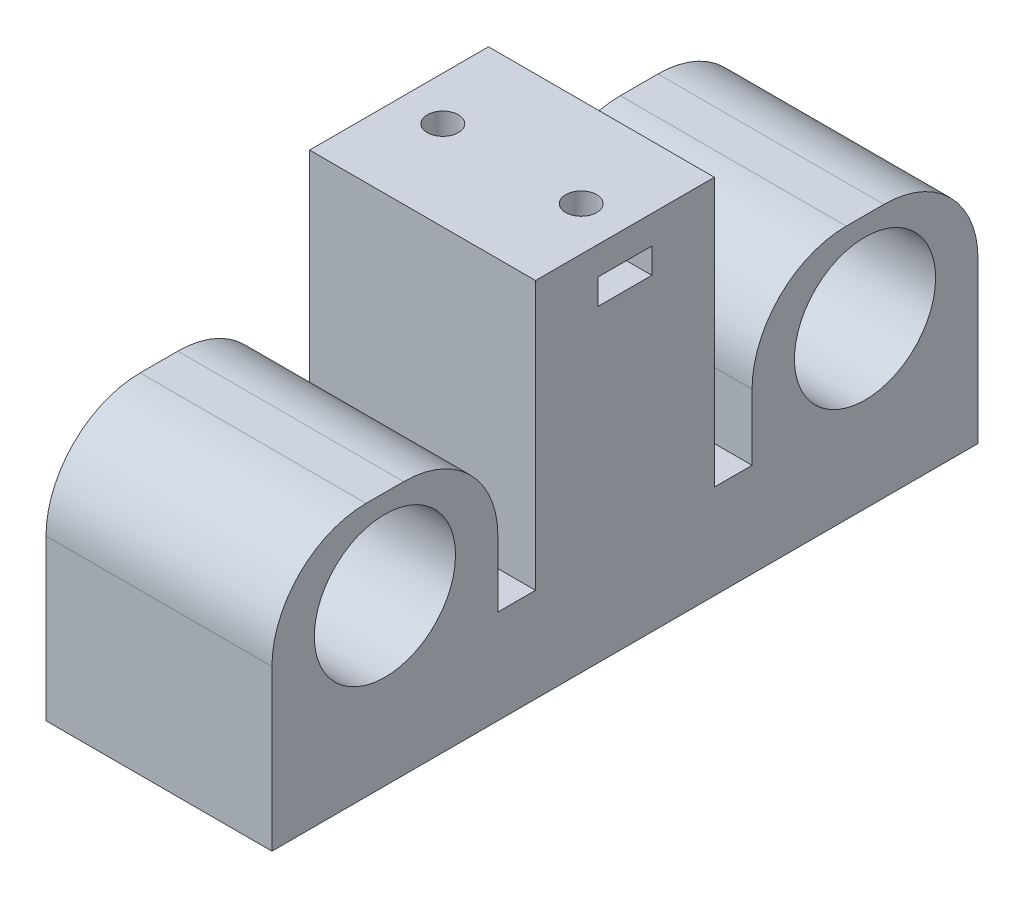
from build123d import *

# Parameters (mm, degrees)
SKETCH1_W           = 24
SKETCH1_H           = 75
BOSS_EXTRUDE1_DEPTH = 10
SKETCH2_W           = 24
SKETCH2_H           = 24
BOSS_EXTRUDE2_DEPTH = 17
SKETCH3_R           = 7.5
CUT_EXTRUDE1_DEPTH  = 25
FILLET1_R           = 10
SKETCH4_W           = 24
SKETCH4_H           = 19
BOSS_EXTRUDE3_DEPTH = 28.5
SKETCH5_W           = 5.7
SKETCH5_H           = 2.7
CUT_EXTRUDE2_DEPTH  = 11
CUT_EXTRUDE3_START  = -24
SKETCH5_2_W         = 5.7
SKETCH5_2_H         = 2.7
CUT_EXTRUDE3_DEPTH  = 11
CUT_EXTRUDE4_REACH  = 40.5
SKETCH6_R           = 1.65


with BuildPart() as part:
    # Sketch1 → Boss-Extrude1 (new body)
    with BuildSketch(Plane(origin=(0, 0, 0), x_dir=(1, 0, 0), z_dir=(0, 1, 0))):
        with Locations((-12, 37.5)):
            Rectangle(SKETCH1_W, SKETCH1_H)
    extrude(amount=BOSS_EXTRUDE1_DEPTH)

    # Sketch2 → Boss-Extrude2 (add)
    with BuildSketch(Plane(origin=(0, 10, 0), x_dir=(1, 0, 0), z_dir=(0, 1, 0))):
        with Locations((-12, 12)):
            Rectangle(SKETCH2_W, SKETCH2_H)
        with Locations((-12, 63)):
            Rectangle(SKETCH2_W, SKETCH2_H)
    extrude(amount=BOSS_EXTRUDE2_DEPTH)

    # Sketch3 → Cut-Extrude1 (cut, through all)
    with BuildSketch(Plane(origin=(0, 0, 0), x_dir=(0, 0, -1), z_dir=(1, 0, 0))):
        with Locations((12, 17.5)):
            Circle(SKETCH3_R)
        with Locations((63, 17.5)):
            Circle(SKETCH3_R)
    extrude(amount=-CUT_EXTRUDE1_DEPTH, mode=Mode.SUBTRACT)

    # Fillet1
    fillet1_edges = [part.edges().sort_by_distance(p)[0] for p in [
        (-12, 27, -51),
        (-12, 27, -24),
        (-12, 27, 0),
        (-12, 27, -75),
    ]]
    fillet(fillet1_edges, radius=FILLET1_R)

    # Sketch4 → Boss-Extrude3 (add)
    with BuildSketch(Plane(origin=(0, 10, 0), x_dir=(1, 0, 0), z_dir=(0, 1, 0))):
        with Locations((-12, 37.5)):
            Rectangle(SKETCH4_W, SKETCH4_H)
    extrude(amount=BOSS_EXTRUDE3_DEPTH)

    # Sketch5 → Cut-Extrude2 (cut)
    with BuildSketch(Plane.ZY.offset(24)):
        with Locations((-37.5, 34.15)):
            Rectangle(SKETCH5_W, SKETCH5_H)
    extrude(amount=-CUT_EXTRUDE2_DEPTH, mode=Mode.SUBTRACT)

    # Sketch5_2 → Cut-Extrude3 (cut)
    with BuildSketch(Plane.ZY.offset(24).offset(CUT_EXTRUDE3_START)):
        with Locations((-37.5, 34.15)):
            Rectangle(SKETCH5_2_W, SKETCH5_2_H)
    extrude(amount=CUT_EXTRUDE3_DEPTH, mode=Mode.SUBTRACT)

    # Sketch6 → Cut-Extrude4 (cut, up to next)
    with BuildSketch(Plane(origin=(0, 38.5, 0), x_dir=(1, 0, 0), z_dir=(0, 1, 0)), mode=Mode.PRIVATE) as cut_extrude4_sk1:
        with Locations((-4.65, 37.5)):
            Circle(SKETCH6_R)
    cut_extrude4_tool1 = extrude(cut_extrude4_sk1.sketch, amount=-CUT_EXTRUDE4_REACH, mode=Mode.PRIVATE) & part.part
    add(cut_extrude4_tool1.solids().sort_by_distance((-4.65, 38.5, -37.5))[0], mode=Mode.SUBTRACT)
    # Sketch6 → Cut-Extrude4 (cut, up to next)
    with BuildSketch(Plane(origin=(0, 38.5, 0), x_dir=(1, 0, 0), z_dir=(0, 1, 0)), mode=Mode.PRIVATE) as cut_extrude4_sk2:
        with Locations((-19.35, 37.5)):
            Circle(SKETCH6_R)
    cut_extrude4_tool2 = extrude(cut_extrude4_sk2.sketch, amount=-CUT_EXTRUDE4_REACH, mode=Mode.PRIVATE) & part.part
    add(cut_extrude4_tool2.solids().sort_by_distance((-19.35, 38.5, -37.5))[0], mode=Mode.SUBTRACT)


solid = part.part
